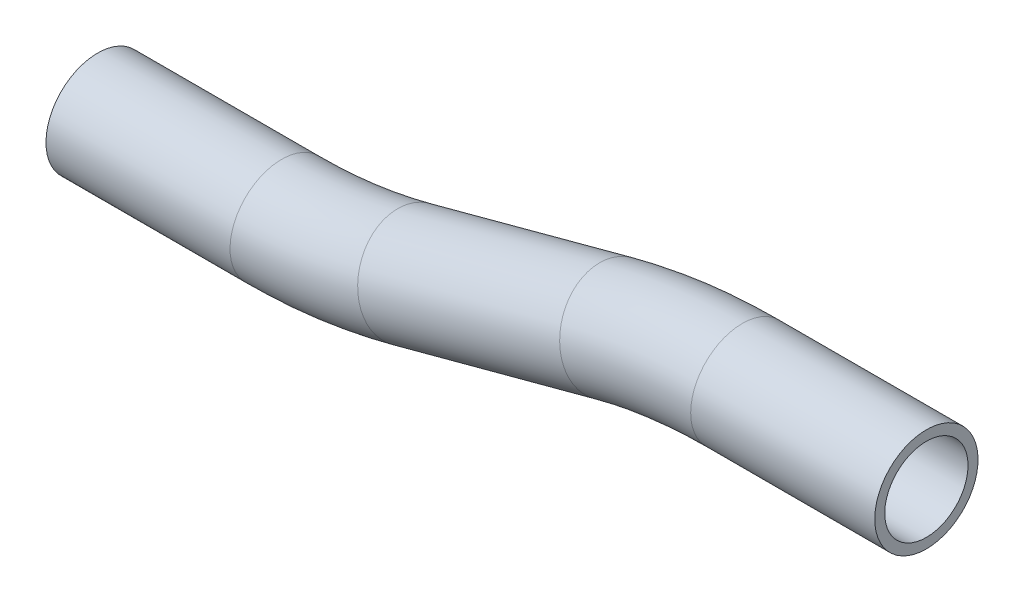
from build123d import *

# Parameters (mm, degrees)
SKETCH2_R   = 7.874
SKETCH2_R_2 = 6.35


with BuildPart() as part:
    # Sweep1: sweep along a path in Sketch1
    with BuildLine(Plane.XY) as sweep1_path:
        Line((28.068079684, 0), (0, 0))
        ThreePointArc((0, 0), (-9.946095847, -0.651901563), (-19.722011237, -2.596452037))
        Line((-19.722011237, -2.596452037), (-50.523992361, -10.849818004))
        ThreePointArc((-50.523992361, -10.849818004), (-60.299907751, -12.794368478), (-70.246003598, -13.446270041))
        Line((-70.246003598, -13.446270041), (-98.314083282, -13.446270041))
    # Sketch2 → Sweep1 (sweep)
    with BuildSketch(Plane.ZY.offset(-28.068079684)):
        Circle(SKETCH2_R)
        Circle(SKETCH2_R_2, mode=Mode.SUBTRACT)
    sweep(path=sweep1_path.line)


solid = part.part
